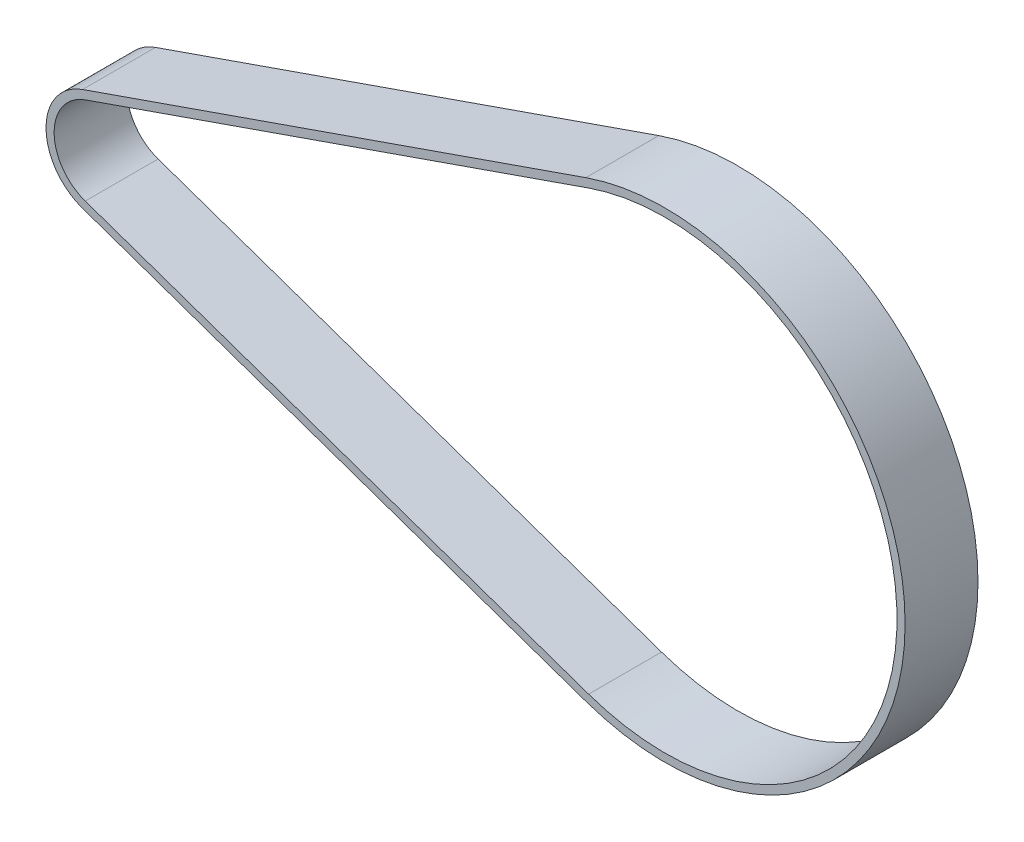
from build123d import *

# Parameters (mm, degrees)
BOSS_EXTRUDE2_DEPTH = 9


with BuildPart() as part:
    # Sketch1 → Boss-Extrude2 (new body)
    with BuildSketch(Plane.XY):
        with BuildLine():
            Line((25.092542018, -28.001467363), (-37.058464724, -6.355157881))
            ThreePointArc((-37.058464724, -6.355157881), (-41.574631799, 0), (-37.058464724, 6.355157881))
            Line((-37.058464724, 6.355157881), (25.092542018, 28.001467363))
            ThreePointArc((25.092542018, 28.001467363), (64.496253847, 0), (25.092542018, -28.001467363))
        make_face()
        with BuildLine():
            Line((25.421449847, -27.057105335), (-36.729556894, -5.410795853))
            ThreePointArc((-36.729556894, -5.410795853), (-40.574631799, 0), (-36.729556894, 5.410795853))
            Line((-36.729556894, 5.410795853), (25.421449847, 27.057105335))
            ThreePointArc((25.421449847, 27.057105335), (63.496253847, 0), (25.421449847, -27.057105335))
        make_face(mode=Mode.SUBTRACT)
    extrude(amount=BOSS_EXTRUDE2_DEPTH)


solid = part.part
